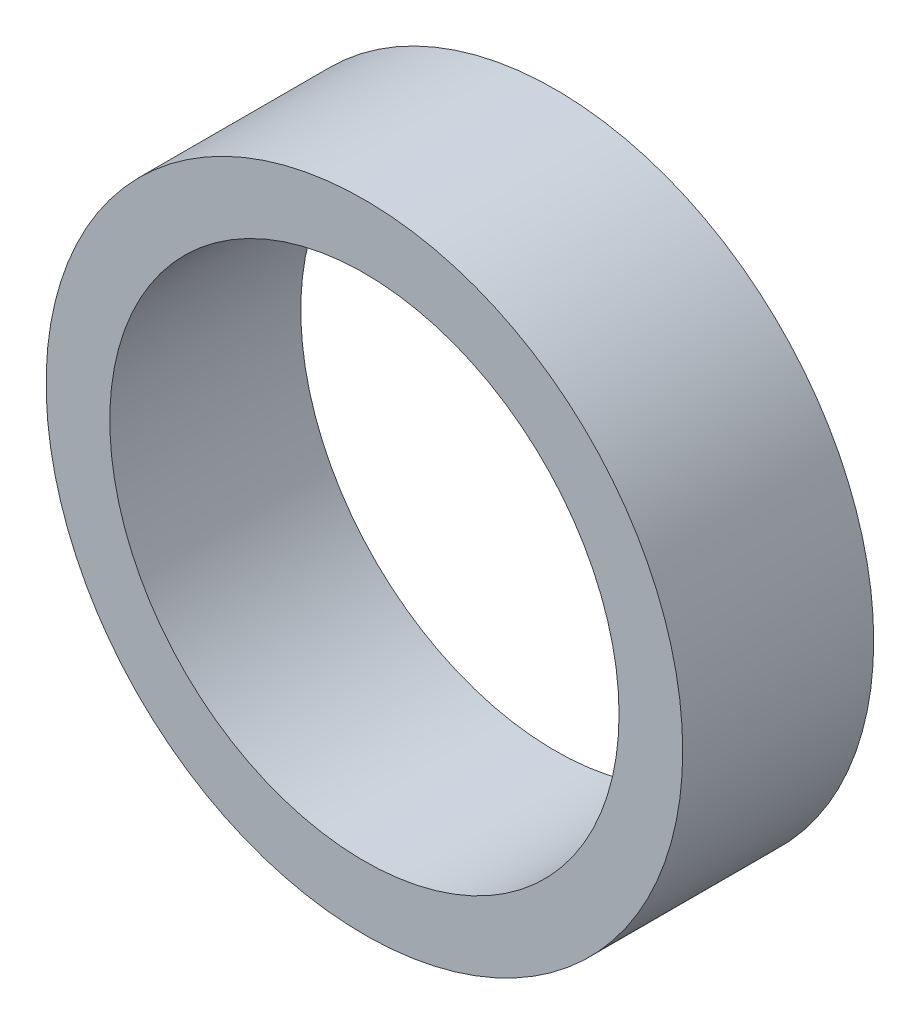
from build123d import *

# Parameters (mm, degrees)
SKETCH1_R           = 25
SKETCH1_R_2         = 20
BOSS_EXTRUDE1_DEPTH = 15


with BuildPart() as part:
    # Sketch1 → Boss-Extrude1 (new body)
    with BuildSketch(Plane.XY):
        Circle(SKETCH1_R)
        Circle(SKETCH1_R_2, mode=Mode.SUBTRACT)
    extrude(amount=BOSS_EXTRUDE1_DEPTH)


solid = part.part
